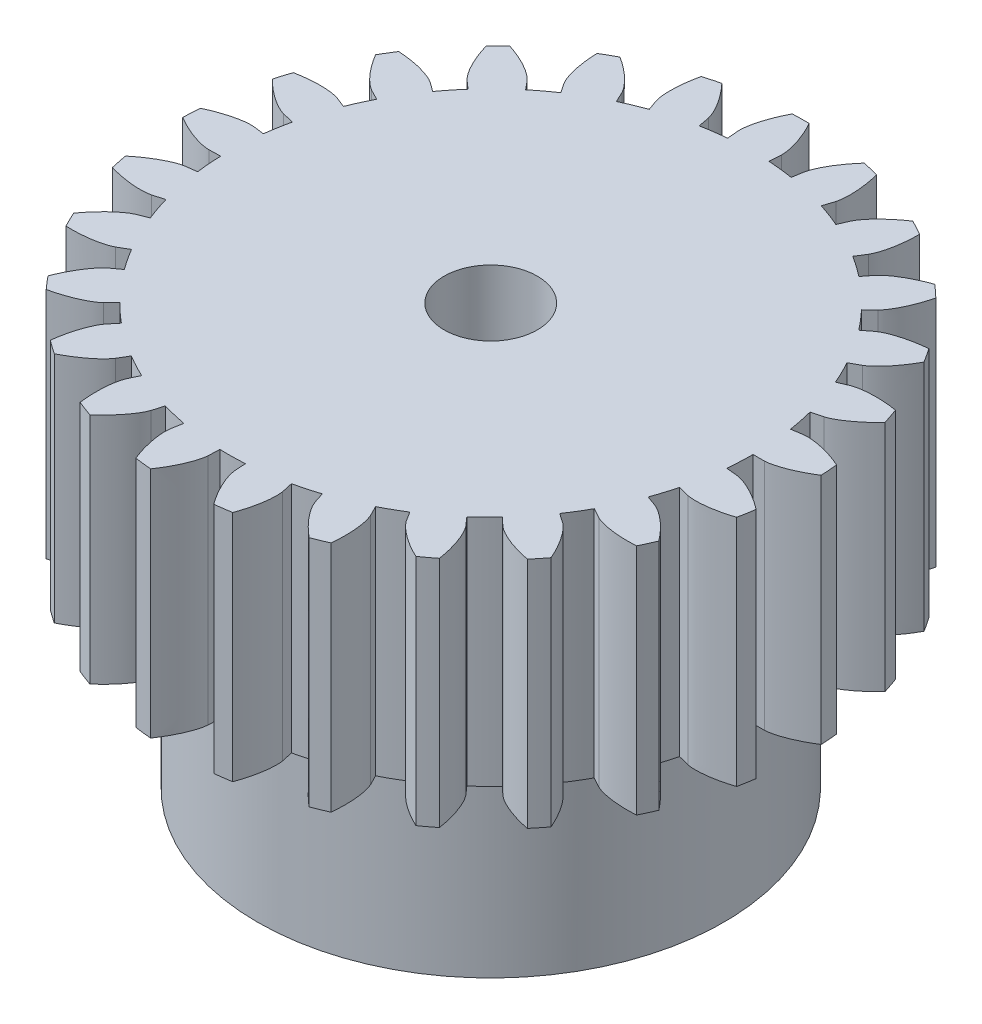
from build123d import *

# Parameters (mm, degrees)
EXTRUDE_1_DEPTH          = 10
PATTERN_CIRCULAR_1_COUNT = 25
SKETCH_3_R               = 2
CUT_EXTRUDE_1_DEPTH      = 11.0000001
SKETCH_4_R               = 10
SKETCH_4_R_2             = 2
EXTRUDE_2_DEPTH          = 8


with BuildPart() as part:
    # 草图2 → 凸台-拉伸1 (new body)
    with BuildSketch(Plane(origin=(0, 0, 0), x_dir=(1, 0, 0), z_dir=(0, 1, 0))):
        with BuildLine():
            ThreePointArc((11.114275129, 1.742236594), (-11.216017457, -0.873757631), (11.25, 0))
            ThreePointArc((11.25, 0), (11.216017457, 0.873757631), (11.114275129, 1.742236594))
        make_face()
        with BuildLine():
            Line((11.25, 0), (11.74615776, 0))
            ThreePointArc((11.74615776, 0), (11.710676488, 0.912292887), (11.604447027, 1.819074301))
            Line((11.604447027, 1.819074301), (11.114275129, 1.742236594))
            ThreePointArc((11.114275129, 1.742236594), (11.216017457, 0.873757631), (11.25, 0))
        make_face()
        with BuildLine():
            ThreePointArc((11.604447027, 1.819074301), (11.710676488, 0.912292887), (11.74615776, 0))
            add(Edge.make_bspline(
                [(11.74615776, 0), (11.790823134, 0.002230776), (11.879701763, 0.010859055), (12.047063697, 0.042294532), (12.234894583, 0.093314147), (12.377081941, 0.140826443), (12.475655836, 0.177536186), (12.498611821, 0.186286216)],
                knots=[0, 0, 0, 0, 0, 0.002802034, 0.005604068, 0.010661158, 0.012202229, 0.012202229, 0.012202229, 0.012202229, 0.012202229], degree=4))
            ThreePointArc((12.498611821, 0.186286216), (12.462241619, 0.970841812), (12.37667246, 1.751564678))
            add(Edge.make_bspline(
                [(11.604447027, 1.819074301), (11.648919009, 1.823787562), (11.738061591, 1.829027609), (11.908272668, 1.82388997), (12.101738657, 1.802574396), (12.24956862, 1.777655222), (12.352638348, 1.756654055), (12.37667246, 1.751564678)],
                knots=[0, 0, 0, 0, 0, 0.002802034, 0.005604068, 0.010661158, 0.012202229, 0.012202229, 0.012202229, 0.012202229, 0.012202229], degree=4))
        make_face()
        with BuildLine():
            ThreePointArc((12.37667246, 1.751564678), (12.462241619, 0.970841812), (12.498611821, 0.186286216))
            add(Edge.make_bspline(
                [(12.498611821, 0.186286216), (12.550986894, 0.206249788), (12.807825836, 0.309329016), (13.056192683, 0.432658365), (13.296221627, 0.57083567), (13.482394228, 0.689235718)],
                knots=[0.012202229, 0.012202229, 0.012202229, 0.012202229, 0.012202229, 0.015718248, 0.029559802, 0.029559802, 0.029559802, 0.029559802, 0.029559802], degree=4))
            ThreePointArc((13.482394228, 0.689235718), (13.459220949, 1.048509157), (13.426475604, 1.407036907))
            add(Edge.make_bspline(
                [(12.37667246, 1.751564678), (12.431507326, 1.739953046), (12.701211065, 1.677892895), (12.965680965, 1.594514894), (13.22421299, 1.495176817), (13.426475604, 1.407036907)],
                knots=[0.012202229, 0.012202229, 0.012202229, 0.012202229, 0.012202229, 0.015718248, 0.029559802, 0.029559802, 0.029559802, 0.029559802, 0.029559802], degree=4))
        make_face()
    extrude_1 = extrude(amount=EXTRUDE_1_DEPTH)

    # 阵列(圆周)1: 凸台-拉伸1 ×25 about axis
    pattern_circular_1_axis = Axis((0, 10, 0), (0, -1, 0))
    for i in range(1, PATTERN_CIRCULAR_1_COUNT):
        add(extrude_1.rotate(pattern_circular_1_axis, i * 360 / PATTERN_CIRCULAR_1_COUNT))

    # 草图3 → 切除-拉伸1 (cut, through all)
    with BuildSketch(Plane(origin=(0, 0, 0), x_dir=(-1, 0, 0), z_dir=(0, -1, 0))):
        Circle(SKETCH_3_R)
    extrude(amount=-CUT_EXTRUDE_1_DEPTH, mode=Mode.SUBTRACT)

    # 草图4 → 凸台-拉伸2 (add)
    with BuildSketch(Plane(origin=(0, 0, 0), x_dir=(-1, 0, 0), z_dir=(0, -1, 0))):
        Circle(SKETCH_4_R)
        Circle(SKETCH_4_R_2, mode=Mode.SUBTRACT)
    extrude(amount=EXTRUDE_2_DEPTH)


solid = part.part
